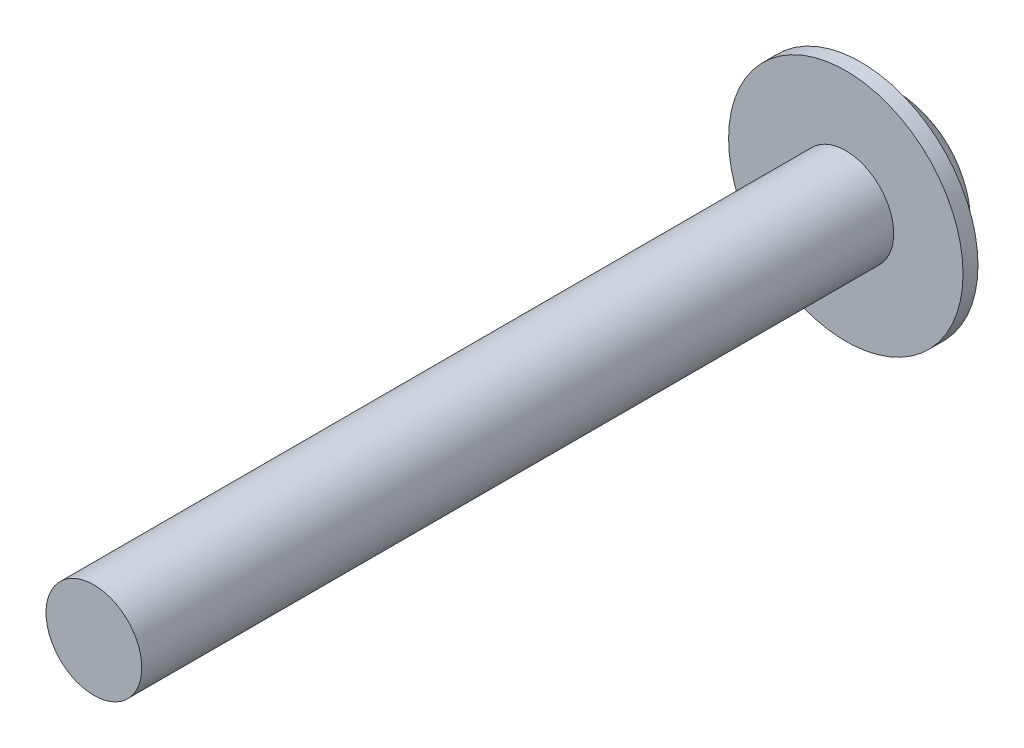
from build123d import *

# Parameters (mm, degrees)
SKETCH1_R      = 1.2192
EXTRUDE1_DEPTH = 19.144
SKETCH2_R      = 2.9845
EXTRUDE2_DEPTH = 0.381
SKETCH3_R      = 2.2479
EXTRUDE3_DEPTH = 1.143
FILLET1_R      = 1.016


with BuildPart() as part:
    # Sketch1 → Extrude1 (new body)
    with BuildSketch(Plane.XY):
        Circle(SKETCH1_R)
    extrude(amount=EXTRUDE1_DEPTH)

    # Sketch2 → Extrude2 (add)
    with BuildSketch(Plane(origin=(0, 0, 0), x_dir=(-1, 0, 0), z_dir=(0, 0, -1))):
        Circle(SKETCH2_R)
    extrude(amount=EXTRUDE2_DEPTH)

    # Sketch3 → Extrude3 (add)
    with BuildSketch(Plane(origin=(0, 0, -0.381), x_dir=(-1, 0, 0), z_dir=(0, 0, -1))):
        Circle(SKETCH3_R)
    extrude(amount=EXTRUDE3_DEPTH)

    # Fillet1
    fillet1_edges = [part.edges().sort_by_distance(p)[0] for p in [
        (2.2479, 0, -1.524),
    ]]
    fillet(fillet1_edges, radius=FILLET1_R)


solid = part.part
